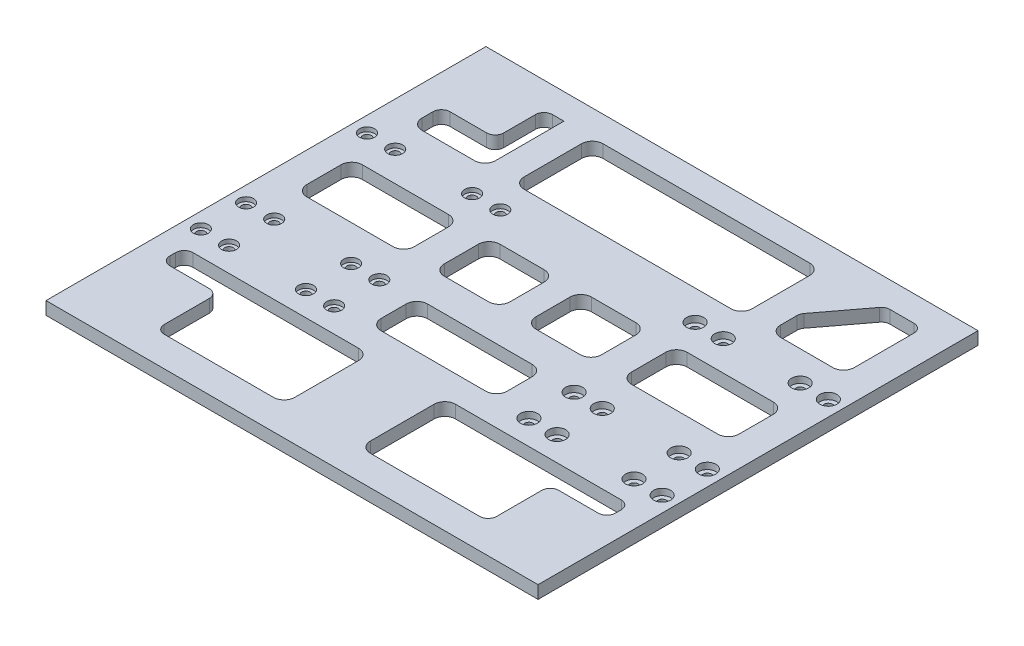
from build123d import *

# Parameters (mm, degrees)
SKETCH1_W           = 115
SKETCH1_H           = 103
BOSS_EXTRUDE1_DEPTH = 3
SKETCH2_R           = 1
CUT_EXTRUDE1_DEPTH  = 10
SKETCH3_W           = 103
SKETCH3_H           = 3
BOSS_EXTRUDE2_DEPTH = 0.1
SKETCH4_W           = 103
SKETCH4_H           = 3
BOSS_EXTRUDE3_DEPTH = 0.1
CUT_EXTRUDE3_DEPTH  = 10
SKETCH8_R           = 2
SKETCH8_R_2         = 2.001116185
CUT_EXTRUDE5_DEPTH  = 1.5
SKETCH7_R           = 1.75
CUT_EXTRUDE4_DEPTH  = 1


with BuildPart() as part:
    # Sketch1 → Boss-Extrude1 (new body)
    with BuildSketch(Plane(origin=(0, 0, 0), x_dir=(1, 0, 0), z_dir=(0, 1, 0))):
        Rectangle(SKETCH1_W, SKETCH1_H)
    extrude(amount=BOSS_EXTRUDE1_DEPTH)

    # Sketch2 → Cut-Extrude1 (cut)
    with BuildSketch(Plane.XZ):
        with Locations((-54, -20.06)):
            Circle(SKETCH2_R)
        with Locations((-54, 8.27)):
            Circle(SKETCH2_R)
        with Locations((-54, 18.84)):
            Circle(SKETCH2_R)
        with Locations((54, -20.06)):
            Circle(SKETCH2_R)
        with Locations((54, 8.27)):
            Circle(SKETCH2_R)
        with Locations((54, 18.84)):
            Circle(SKETCH2_R)
        with Locations((-47.4, 18.84)):
            Circle(SKETCH2_R)
        with Locations((-47.4, -20.06)):
            Circle(SKETCH2_R)
        with Locations((-47.4, 8.27)):
            Circle(SKETCH2_R)
        with Locations((47.4, -20.06)):
            Circle(SKETCH2_R)
        with Locations((47.4, 8.27)):
            Circle(SKETCH2_R)
        with Locations((47.4, 18.84)):
            Circle(SKETCH2_R)
        with Locations((-29.4, 18.84)):
            Circle(SKETCH2_R)
        with Locations((-22.8, 18.84)):
            Circle(SKETCH2_R)
        with Locations((-22.8, 8.27)):
            Circle(SKETCH2_R)
        with Locations((-29.4, 8.27)):
            Circle(SKETCH2_R)
        with Locations((-22.8, -20.06)):
            Circle(SKETCH2_R)
        with Locations((-29.4, -20.06)):
            Circle(SKETCH2_R)
        with Locations((22.8, 18.84)):
            Circle(SKETCH2_R)
        with Locations((29.4, 18.84)):
            Circle(SKETCH2_R)
        with Locations((29.4, 8.27)):
            Circle(SKETCH2_R)
        with Locations((22.8, 8.27)):
            Circle(SKETCH2_R)
        with Locations((29.4, -20.06)):
            Circle(SKETCH2_R)
        with Locations((22.8, -20.06)):
            Circle(SKETCH2_R)
    extrude(amount=-CUT_EXTRUDE1_DEPTH, mode=Mode.SUBTRACT)

    # Sketch3 → Boss-Extrude2 (add)
    with BuildSketch(Plane.ZY.offset(57.5)):
        with Locations((0, 1.5)):
            Rectangle(SKETCH3_W, SKETCH3_H)
    extrude(amount=BOSS_EXTRUDE2_DEPTH)

    # Sketch4 → Boss-Extrude3 (add)
    with BuildSketch(Plane(origin=(57.5, 0, 0), x_dir=(0, 0, -1), z_dir=(1, 0, 0))):
        with Locations((0, 1.5)):
            Rectangle(SKETCH4_W, SKETCH4_H)
    extrude(amount=BOSS_EXTRUDE3_DEPTH)

    # Sketch6 → Cut-Extrude3 (cut)
    with BuildSketch(Plane(origin=(0, 3, 0), x_dir=(1, 0, 0), z_dir=(0, 1, 0))):
        with BuildLine():
            ThreePointArc((-38.013551844, 36.080628064), (-38.599338282, 34.666414502), (-40.013551844, 34.080628064))
            Line((-40.013551844, 34.080628064), (-48.6, 34.080628064))
            ThreePointArc((-48.6, 34.080628064), (-50.014213562, 33.494841626), (-50.6, 32.080628064))
            Line((-50.6, 32.080628064), (-50.6, 29.525557041))
            ThreePointArc((-50.6, 29.525557041), (-49.867766953, 27.757790088), (-48.1, 27.025557041))
            Line((-48.1, 27.025557041), (-35.846467966, 27.025557041))
            ThreePointArc((-35.846467966, 27.025557041), (-34.078701013, 27.757790088), (-33.346467966, 29.525557041))
            Line((-33.346467966, 29.525557041), (-33.346467966, 34.080628064))
            Line((-33.346467966, 34.080628064), (-33.346467966, 45.5))
            Line((-33.346467966, 45.5), (-36.013551844, 45.5))
            ThreePointArc((-36.013551844, 45.5), (-37.427765406, 44.914213562), (-38.013551844, 43.5))
            Line((-38.013551844, 43.5), (-38.013551844, 36.080628064))
        make_face()
        with BuildLine():
            Line((24.211357367, 45.5), (-24.211357367, 45.5))
            ThreePointArc((-24.211357367, 45.5), (-25.97912432, 44.767766953), (-26.711357367, 43))
            Line((-26.711357367, 43), (-26.711357367, 29.525557041))
            ThreePointArc((-26.711357367, 29.525557041), (-25.97912432, 27.757790088), (-24.211357367, 27.025557041))
            Line((-24.211357367, 27.025557041), (24.211357367, 27.025557041))
            ThreePointArc((24.211357367, 27.025557041), (25.97912432, 27.757790088), (26.711357367, 29.525557041))
            Line((26.711357367, 29.525557041), (26.711357367, 43))
            ThreePointArc((26.711357367, 43), (25.97912432, 44.767766953), (24.211357367, 45.5))
        make_face()
        with BuildLine():
            ThreePointArc((-50.154158752, -24.575396294), (-51.568372314, -25.161182732), (-52.154158752, -26.575396294))
            Line((-52.154158752, -26.575396294), (-52.154158752, -27.95379319))
            ThreePointArc((-52.154158752, -27.95379319), (-51.568372314, -29.368006753), (-50.154158752, -29.95379319))
            Line((-50.154158752, -29.95379319), (-40.915829131, -29.95379319))
            ThreePointArc((-40.915829131, -29.95379319), (-39.501615569, -30.539579628), (-38.915829131, -31.95379319))
            Line((-38.915829131, -31.95379319), (-38.915829131, -42.5))
            ThreePointArc((-38.915829131, -42.5), (-38.330042694, -43.914213562), (-36.915829131, -44.5))
            Line((-36.915829131, -44.5), (-11.348843163, -44.5))
            ThreePointArc((-11.348843163, -44.5), (-9.58107621, -43.767766953), (-8.848843163, -42))
            Line((-8.848843163, -42), (-8.848843163, -27.075396294))
            ThreePointArc((-8.848843163, -27.075396294), (-9.58107621, -25.307629341), (-11.348843163, -24.575396294))
            Line((-11.348843163, -24.575396294), (-50.154158752, -24.575396294))
        make_face()
        with BuildLine():
            ThreePointArc((-50.6, 2.556382832), (-49.867766953, 0.788615879), (-48.1, 0.056382832))
            Line((-48.1, 0.056382832), (-27.927103688, 0.056382832))
            ThreePointArc((-27.927103688, 0.056382832), (-26.159336735, 0.788615879), (-25.427103688, 2.556382832))
            Line((-25.427103688, 2.556382832), (-25.427103688, 10.569015944))
            ThreePointArc((-25.427103688, 10.569015944), (-26.159336735, 12.336782897), (-27.927103688, 13.069015944))
            Line((-27.927103688, 13.069015944), (-48.1, 13.069015944))
            ThreePointArc((-48.1, 13.069015944), (-49.867766953, 12.336782897), (-50.6, 10.569015944))
            Line((-50.6, 10.569015944), (-50.6, 2.556382832))
        make_face()
        with BuildLine():
            ThreePointArc((-18.41791754, 2.556382832), (-17.685684493, 0.788615879), (-15.91791754, 0.056382832))
            Line((-15.91791754, 0.056382832), (-5.533746838, 0.056382832))
            ThreePointArc((-5.533746838, 0.056382832), (-3.765979885, 0.788615879), (-3.033746838, 2.556382832))
            Line((-3.033746838, 2.556382832), (-3.033746838, 10.569015944))
            ThreePointArc((-3.033746838, 10.569015944), (-3.765979885, 12.336782897), (-5.533746838, 13.069015944))
            Line((-5.533746838, 13.069015944), (-15.91791754, 13.069015944))
            ThreePointArc((-15.91791754, 13.069015944), (-17.685684493, 12.336782897), (-18.41791754, 10.569015944))
            Line((-18.41791754, 10.569015944), (-18.41791754, 2.556382832))
        make_face()
        with BuildLine():
            Line((8.848843163, -27.075396294), (8.848843163, -42))
            ThreePointArc((8.848843163, -42), (9.58107621, -43.767766953), (11.348843163, -44.5))
            Line((11.348843163, -44.5), (36.915829131, -44.5))
            ThreePointArc((36.915829131, -44.5), (38.330042694, -43.914213562), (38.915829131, -42.5))
            Line((38.915829131, -42.5), (38.915829131, -31.95379319))
            ThreePointArc((38.915829131, -31.95379319), (39.501615569, -30.539579628), (40.915829131, -29.95379319))
            Line((40.915829131, -29.95379319), (50.154158752, -29.95379319))
            ThreePointArc((50.154158752, -29.95379319), (51.568372314, -29.368006753), (52.154158752, -27.95379319))
            Line((52.154158752, -27.95379319), (52.154158752, -26.575396294))
            ThreePointArc((52.154158752, -26.575396294), (51.568372314, -25.161182732), (50.154158752, -24.575396294))
            Line((50.154158752, -24.575396294), (11.348843163, -24.575396294))
            ThreePointArc((11.348843163, -24.575396294), (9.58107621, -25.307629341), (8.848843163, -27.075396294))
        make_face()
        with BuildLine():
            ThreePointArc((-14.750112184, -15.896518995), (-14.017879137, -17.664285948), (-12.250112184, -18.396518995))
            Line((-12.250112184, -18.396518995), (12.250112184, -18.396518995))
            ThreePointArc((12.250112184, -18.396518995), (14.017879137, -17.664285948), (14.750112184, -15.896518995))
            Line((14.750112184, -15.896518995), (14.750112184, -10.023618282))
            ThreePointArc((14.750112184, -10.023618282), (14.017879137, -8.255851329), (12.250112184, -7.523618282))
            Line((12.250112184, -7.523618282), (-12.250112184, -7.523618282))
            ThreePointArc((-12.250112184, -7.523618282), (-14.017879137, -8.255851329), (-14.750112184, -10.023618282))
            Line((-14.750112184, -10.023618282), (-14.750112184, -15.896518995))
        make_face()
        with BuildLine():
            Line((3.033746838, 10.569015944), (3.033746838, 2.556382832))
            ThreePointArc((3.033746838, 2.556382832), (3.765979885, 0.788615879), (5.533746838, 0.056382832))
            Line((5.533746838, 0.056382832), (15.91791754, 0.056382832))
            ThreePointArc((15.91791754, 0.056382832), (17.685684493, 0.788615879), (18.41791754, 2.556382832))
            Line((18.41791754, 2.556382832), (18.41791754, 10.569015944))
            ThreePointArc((18.41791754, 10.569015944), (17.685684493, 12.336782897), (15.91791754, 13.069015944))
            Line((15.91791754, 13.069015944), (5.533746838, 13.069015944))
            ThreePointArc((5.533746838, 13.069015944), (3.765979885, 12.336782897), (3.033746838, 10.569015944))
        make_face()
        with BuildLine():
            Line((27.927103688, 0.056382832), (48.1, 0.056382832))
            ThreePointArc((48.1, 0.056382832), (49.867766953, 0.788615879), (50.6, 2.556382832))
            Line((50.6, 2.556382832), (50.6, 10.569015944))
            ThreePointArc((50.6, 10.569015944), (49.867766953, 12.336782897), (48.1, 13.069015944))
            Line((48.1, 13.069015944), (27.927103688, 13.069015944))
            ThreePointArc((27.927103688, 13.069015944), (26.159336735, 12.336782897), (25.427103688, 10.569015944))
            Line((25.427103688, 10.569015944), (25.427103688, 2.556382832))
            ThreePointArc((25.427103688, 2.556382832), (26.159336735, 0.788615879), (27.927103688, 0.056382832))
        make_face()
        with BuildLine():
            Line((35.846467966, 27.025557041), (48.1, 27.025557041))
            ThreePointArc((48.1, 27.025557041), (49.867766953, 27.757790088), (50.6, 29.525557041))
            Line((50.6, 29.525557041), (50.6, 43.5))
            ThreePointArc((50.6, 43.5), (50.014213562, 44.914213562), (48.6, 45.5))
            Line((48.6, 45.5), (42.968889048, 45.5))
            ThreePointArc((42.968889048, 45.5), (42.077574892, 45.290407517), (41.373073483, 44.705559076))
            Line((41.373073483, 44.705559076), (33.750652402, 34.615652706))
            ThreePointArc((33.750652402, 34.615652706), (33.450204386, 34.045848643), (33.346467966, 33.410093631))
            Line((33.346467966, 33.410093631), (33.346467966, 29.525557041))
            ThreePointArc((33.346467966, 29.525557041), (34.078701013, 27.757790088), (35.846467966, 27.025557041))
        make_face()
    extrude(amount=-CUT_EXTRUDE3_DEPTH, mode=Mode.SUBTRACT)

    # Sketch8 → Cut-Extrude5 (cut)
    with BuildSketch(Plane(origin=(0, 3, 0), x_dir=(1, 0, 0), z_dir=(0, 1, 0))):
        with Locations((54, -18.84)):
            Circle(SKETCH8_R)
        with Locations((47.4, -18.84)):
            Circle(SKETCH8_R_2)
        with Locations((54, -8.27)):
            Circle(SKETCH8_R)
        with Locations((47.4, -8.27)):
            Circle(SKETCH8_R)
        with Locations((54, 20.06)):
            Circle(SKETCH8_R)
        with Locations((47.4, 20.06)):
            Circle(SKETCH8_R)
        with Locations((29.4, 20.06)):
            Circle(SKETCH8_R)
        with Locations((22.8, 20.06)):
            Circle(SKETCH8_R)
        with Locations((22.8, -18.84)):
            Circle(SKETCH8_R)
        with Locations((29.4, -18.84)):
            Circle(SKETCH8_R)
        with Locations((29.4, -8.27)):
            Circle(SKETCH8_R)
        with Locations((22.8, -8.27)):
            Circle(SKETCH8_R)
    extrude(amount=-CUT_EXTRUDE5_DEPTH, mode=Mode.SUBTRACT)

    # Sketch7 → Cut-Extrude4 (cut)
    with BuildSketch(Plane(origin=(0, 3, 0), x_dir=(1, 0, 0), z_dir=(0, 1, 0))):
        with Locations((-54, 20.06)):
            Circle(SKETCH7_R)
        with Locations((-47.4, 20.06)):
            Circle(SKETCH7_R)
        with Locations((-54, -8.27)):
            Circle(SKETCH7_R)
        with Locations((-47.4, -8.27)):
            Circle(SKETCH7_R)
        with Locations((-54, -18.84)):
            Circle(SKETCH7_R)
        with Locations((-47.4, -18.84)):
            Circle(SKETCH7_R)
        with Locations((-29.4, -18.84)):
            Circle(SKETCH7_R)
        with Locations((-22.8, -18.84)):
            Circle(SKETCH7_R)
        with Locations((-29.4, -8.27)):
            Circle(SKETCH7_R)
        with Locations((-22.8, -8.27)):
            Circle(SKETCH7_R)
        with Locations((-22.8, 20.06)):
            Circle(SKETCH7_R)
        with Locations((-29.4, 20.06)):
            Circle(SKETCH7_R)
        with Locations((22.8, -18.84)):
            Circle(SKETCH7_R)
        with Locations((29.4, -18.84)):
            Circle(SKETCH7_R)
        with Locations((47.4, -18.84)):
            Circle(SKETCH7_R)
        with Locations((54, -18.84)):
            Circle(SKETCH7_R)
        with Locations((22.8, -8.27)):
            Circle(SKETCH7_R)
        with Locations((29.4, -8.27)):
            Circle(SKETCH7_R)
        with Locations((47.4, -8.27)):
            Circle(SKETCH7_R)
        with Locations((54, -8.27)):
            Circle(SKETCH7_R)
        with Locations((22.8, 20.06)):
            Circle(SKETCH7_R)
        with Locations((29.4, 20.06)):
            Circle(SKETCH7_R)
        with Locations((47.4, 20.06)):
            Circle(SKETCH7_R)
        with Locations((54, 20.06)):
            Circle(SKETCH7_R)
    extrude(amount=-CUT_EXTRUDE4_DEPTH, mode=Mode.SUBTRACT)


solid = part.part
